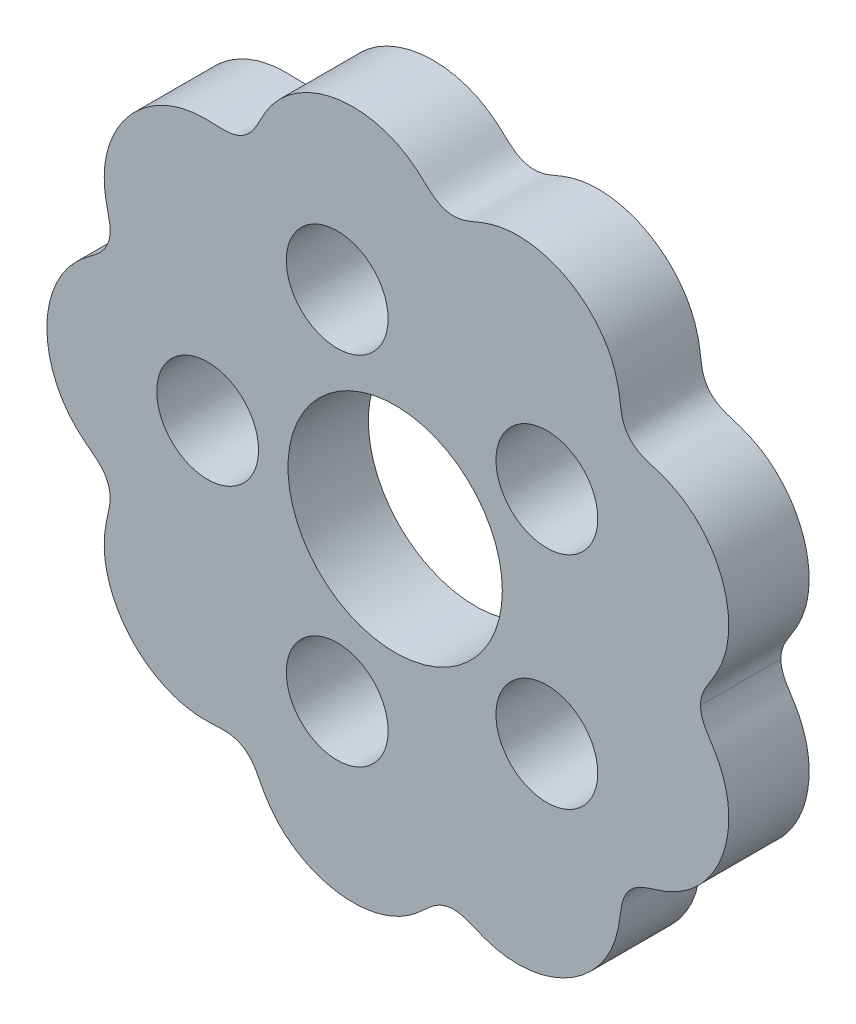
from build123d import *

# Parameters (mm, degrees)
EXTRUDE_1_DEPTH     = 3
SKETCH_3_R          = 4
CUT_EXTRUDE_1_DEPTH = 3
SKETCH_4_R          = 1.9
CUT_EXTRUDE_2_DEPTH = 3


with BuildPart() as part:
    # 草图1 → 凸台-拉伸1 (new body)
    with BuildSketch(Plane.XY):
        with BuildLine():
            add(Edge.make_bspline(
                [(11.399998992, 1.8185e-05), (11.399998992, -0.000673615), (11.400041568, -0.054759063), (11.406734501, -0.162228792), (11.436381463, -0.321229934), (11.510321001, -0.522501307), (11.610250666, -0.711714618), (11.724113706, -0.892470353), (11.86937368, -1.116439341), (12.07499003, -1.460911491), (12.293086995, -1.952023996), (12.450033679, -2.60719425), (12.474844361, -3.360912431), (12.353755332, -4.105031989), (12.094338519, -4.81256214), (11.706001426, -5.458586889), (11.1999284, -6.017330981), (10.657075772, -6.415758462), (10.124705247, -6.672330774), (9.641766396, -6.828922045), (9.230611434, -6.946368272), (8.852870657, -7.160423455), (8.574936004, -7.499908551), (8.43897686, -7.911933411), (8.396885896, -8.337382783), (8.32301433, -8.840270006), (8.158200259, -9.408069794), (7.854940636, -10.009861306), (7.387707562, -10.602008331), (6.813596246, -11.093542999), (6.155713169, -11.468308329), (5.436736024, -11.711609958), (4.776707214, -11.798136019), (4.207741628, -11.774893585), (3.732084251, -11.687500603), (3.348855318, -11.572738112), (2.970578529, -11.416780061), (2.585078287, -11.247896033), (2.162323261, -11.176738824), (1.736200775, -11.262166935), (1.370948612, -11.492338232), (1.066034702, -11.791267153), (0.688211492, -12.125576363), (0.202860176, -12.449660037), (-0.405513689, -12.712153577), (-1.128731566, -12.866209727), (-2.060078184, -12.883588279), (-2.977435494, -12.66772774), (-3.815344558, -12.22559869), (-4.444531822, -11.635224063), (-4.794466544, -11.158656215), (-5.036520625, -10.711511695), (-5.221262286, -10.326046136), (-5.487323337, -9.985545404), (-5.859813632, -9.761125083), (-6.281848829, -9.685368156), (-6.701706056, -9.712651752), (-7.205221005, -9.733469113), (-7.793667005, -9.679268824), (-8.444831768, -9.494414916), (-9.119552083, -9.142653714), (-9.711167266, -8.667039171), (-10.200380634, -8.089199677), (-10.570677857, -7.430374989), (-10.806098063, -6.713884626), (-10.884119206, -6.044612484), (-10.843879592, -5.454820358), (-10.740613607, -4.957236088), (-10.635058549, -4.542961708), (-10.62376503, -4.109142556), (-10.770901199, -3.695817928), (-11.053972475, -3.366720611), (-11.400666639, -3.116273956), (-11.726418533, -2.860839525), (-12.015833563, -2.582001565), (-12.263892699, -2.283286284), (-12.47247866, -1.971298872), (-12.647750903, -1.639578416), (-12.789078003, -1.292021275), (-12.895599328, -0.932326892), (-12.966924102, -0.564001469), (-12.993938457, -0.283223761), (-12.999981728, -0.095172404), (-13.000000291, -0.000762786), (-13.000000244, 0)],
                knots=[0.119653037, 0.119653037, 0.119653037, 0.119653037, 0.119653037, 0.119702875, 0.123549437, 0.127395999, 0.131242561, 0.135089123, 0.138935684, 0.142782246, 0.15047537, 0.163970387, 0.177465404, 0.190960422, 0.204455439, 0.217945209, 0.231434979, 0.244924749, 0.258414519, 0.266104686, 0.273794852, 0.281485019, 0.289175185, 0.296870304, 0.304565423, 0.312260542, 0.319955661, 0.333454153, 0.346952646, 0.360451138, 0.373949631, 0.387561798, 0.401173966, 0.414786134, 0.421592218, 0.428398301, 0.435960585, 0.443522869, 0.451085154, 0.458647438, 0.466336371, 0.474025305, 0.481714239, 0.489403173, 0.502638698, 0.515874223, 0.529109748, 0.542345274, 0.569345726, 0.582845953, 0.596346179, 0.604042304, 0.611738429, 0.619434554, 0.627130679, 0.634693899, 0.642257119, 0.649820338, 0.657383558, 0.670997536, 0.684611515, 0.698225493, 0.711839471, 0.725336227, 0.738832984, 0.75232974, 0.765826496, 0.773520615, 0.781214734, 0.788908852, 0.796602971, 0.804294119, 0.811985267, 0.819676416, 0.827367564, 0.834113326, 0.840859089, 0.847604851, 0.854350614, 0.861096377, 0.867842139, 0.874587902, 0.881333664, 0.881388611, 0.881388611, 0.881388611, 0.881388611, 0.881388611], degree=4))
            add(Edge.make_bspline(
                [(11.399998992, 1.8185e-05), (11.399999002, 0.000705439), (11.400042093, 0.05478634), (11.406735218, 0.162251476), (11.436381223, 0.321248146), (11.510320611, 0.522519574), (11.610250136, 0.71173296), (11.724113041, 0.892488779), (11.869372848, 1.116457876), (12.074988941, 1.460930179), (12.293085541, 1.952042846), (12.450031736, 2.607213218), (12.474841856, 3.360931417), (12.353752272, 4.105050885), (12.094334933, 4.812580843), (11.705997357, 5.458605302), (11.199923915, 6.017349017), (10.657070991, 6.415776093), (10.124700274, 6.672348009), (9.641761306, 6.82893892), (9.230606257, 6.94638484), (8.852865321, 7.160439742), (8.574930415, 7.499924631), (8.438970963, 7.91194939), (8.396879683, 8.33739873), (8.323007741, 8.840285898), (8.158193247, 9.408085563), (7.854933176, 10.009876849), (7.387699661, 10.602023526), (6.813587978, 11.093557766), (6.155704622, 11.468322606), (5.436727295, 11.711623699), (4.776698421, 11.798149268), (4.207732853, 11.77490641), (3.73207554, 11.687513074), (3.348846693, 11.572750297), (2.97057002, 11.416791964), (2.585069904, 11.247907649), (2.162314931, 11.176750124), (1.736192381, 11.262177917), (1.370940047, 11.492348943), (1.066025914, 11.791277637), (0.688202455, 12.125586565), (0.202850898, 12.449669877), (-0.405523163, 12.712162963), (-1.128741155, 12.866218575), (-2.060087786, 12.883596432), (-2.977444935, 12.66773521), (-3.81535367, 12.225605536), (-4.444540494, 11.635230439), (-4.794474861, 11.15866233), (-5.036528608, 10.71151763), (-5.221269982, 10.326051934), (-5.487330779, 9.985551003), (-5.859820907, 9.761130405), (-6.281856047, 9.685373163), (-6.701713295, 9.712656446), (-7.205228259, 9.733473431), (-7.793674219, 9.679272705), (-8.444838844, 9.494418311), (-9.119558897, 9.142656606), (-9.711173726, 8.667041622), (-10.200386663, 8.089201763), (-10.570683395, 7.4303768), (-10.806103067, 6.713886261), (-10.884123711, 6.044614061), (-10.843883658, 5.454821965), (-10.740617302, 4.957237772), (-10.635061935, 4.542963471), (-10.623768092, 4.109144327), (-10.770903953, 3.695819589), (-11.053974985, 3.366722061), (-11.400668961, 3.116275148), (-11.726420665, 2.860840474), (-12.015835487, 2.582002298), (-12.263894401, 2.283286832), (-12.472480129, 1.971299265), (-12.647752125, 1.639578678), (-12.789078966, 1.292021432), (-12.895600023, 0.93232697), (-12.966924522, 0.564001494), (-12.993938668, 0.283223766), (-12.999981799, 0.095172404), (-13.000000291, 0.000762786), (-13.000000244, 0)],
                knots=[0.119653364, 0.119653364, 0.119653364, 0.119653364, 0.119653364, 0.119702875, 0.123549437, 0.127395999, 0.131242561, 0.135089123, 0.138935684, 0.142782246, 0.15047537, 0.163970387, 0.177465404, 0.190960422, 0.204455439, 0.217945209, 0.231434979, 0.244924749, 0.258414519, 0.266104686, 0.273794852, 0.281485019, 0.289175185, 0.296870304, 0.304565423, 0.312260542, 0.319955661, 0.333454153, 0.346952646, 0.360451138, 0.373949631, 0.387561798, 0.401173966, 0.414786134, 0.421592218, 0.428398301, 0.435960585, 0.443522869, 0.451085154, 0.458647438, 0.466336371, 0.474025305, 0.481714239, 0.489403173, 0.502638698, 0.515874223, 0.529109748, 0.542345274, 0.569345726, 0.582845953, 0.596346179, 0.604042304, 0.611738429, 0.619434554, 0.627130679, 0.634693899, 0.642257119, 0.649820338, 0.657383558, 0.670997536, 0.684611515, 0.698225493, 0.711839471, 0.725336227, 0.738832984, 0.75232974, 0.765826496, 0.773520615, 0.781214734, 0.788908852, 0.796602971, 0.804294119, 0.811985267, 0.819676416, 0.827367564, 0.834113326, 0.840859089, 0.847604851, 0.854350614, 0.861096377, 0.867842139, 0.874587902, 0.881333664, 0.881388611, 0.881388611, 0.881388611, 0.881388611, 0.881388611], degree=4))
        make_face()
    extrude(amount=EXTRUDE_1_DEPTH)

    # 草图3 → 切除-拉伸1 (cut)
    with BuildSketch(Plane.XY.offset(3)):
        Circle(SKETCH_3_R)
    extrude(amount=-CUT_EXTRUDE_1_DEPTH, mode=Mode.SUBTRACT)

    # 草图4 → 切除-拉伸2 (cut)
    with BuildSketch(Plane.XY.offset(3)):
        with Locations((-7, 0)):
            Circle(SKETCH_4_R)
        with Locations((-2.163118961, 6.657395614)):
            Circle(SKETCH_4_R)
        with Locations((5.663118961, 4.114496766)):
            Circle(SKETCH_4_R)
        with Locations((5.663118961, -4.114496766)):
            Circle(SKETCH_4_R)
        with Locations((-2.163118961, -6.657395614)):
            Circle(SKETCH_4_R)
    extrude(amount=-CUT_EXTRUDE_2_DEPTH, mode=Mode.SUBTRACT)


solid = part.part
